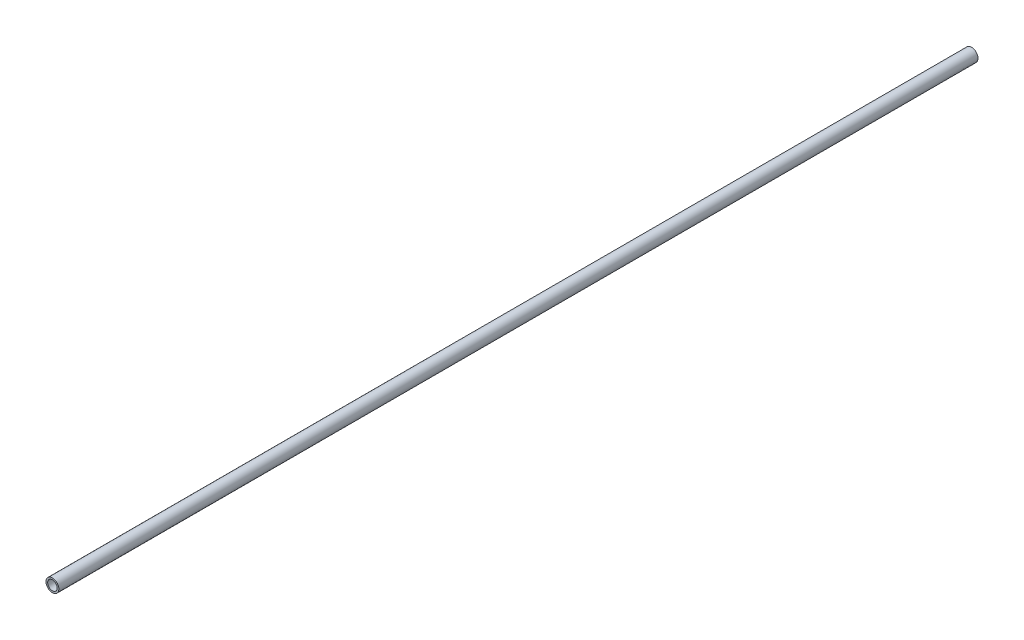
from build123d import *

# Parameters (mm, degrees)
SKETCH1_R           = 10.668
SKETCH1_R_2         = 7.8994
EXTRUDE_THIN1_DEPTH = 762


with BuildPart() as part:
    # Sketch1 → Extrude-Thin1 (new body, symmetric)
    with BuildSketch(Plane.XY):
        Circle(SKETCH1_R)
        Circle(SKETCH1_R_2, mode=Mode.SUBTRACT)
    extrude(amount=EXTRUDE_THIN1_DEPTH, both=True)


solid = part.part
